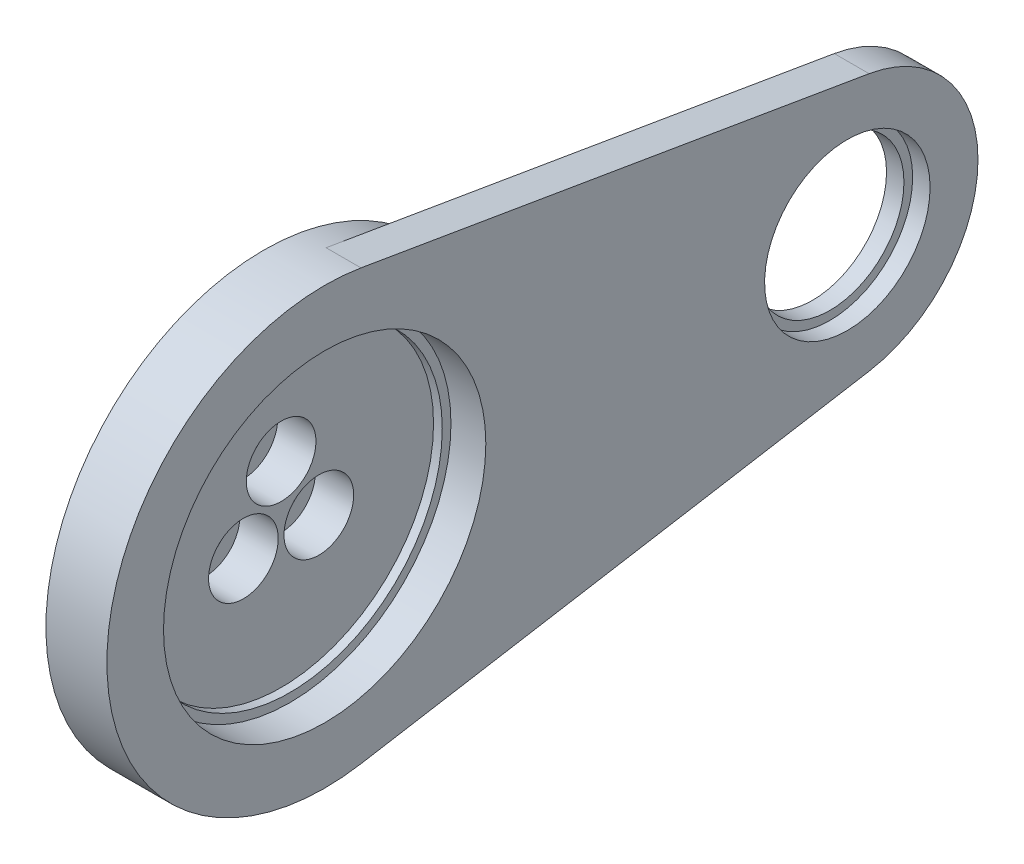
from build123d import *

# Parameters (mm, degrees)
SKETCH_3_R                   = 25
EXTRUDE_1_DEPTH              = 2
SKETCH_4_R                   = 25
SKETCH_4_R_2                 = 17.5
EXTRUDE_2_DEPTH              = 1
SKETCH_5_R                   = 25
SKETCH_5_R_2                 = 18.5
EXTRUDE_3_DEPTH              = 7
SKETCH_6_R                   = 25
SKETCH_6_R_2                 = 17.5
EXTRUDE_4_DEPTH              = 2
EXTRUDE_5_DEPTH              = 9
SKETCH_11_R                  = 8.5
CUT_EXTRUDE_3_DEPTH          = 111
SKETCH_12_R                  = 9.5
CUT_EXTRUDE_4_DEPTH          = 2.5
SKETCH_13_R                  = 9.5
EXTRUDE_6_DEPTH              = 5
HOLE_WIZARD_M4_1_D           = 4.5
HOLE_WIZARD_M4_1_CBORE_D     = 8
HOLE_WIZARD_M4_1_CBORE_DEPTH = 4.4
PATTERN_CIRCULAR_1_COUNT     = 3
SKETCH_17_W                  = 17.714059585
SKETCH_17_H                  = 64.604217311
CUT_EXTRUDE_5_DEPTH          = 1111


with BuildPart() as part:
    # 스케치3 → 보스-돌출1 (new body)
    with BuildSketch(Plane(origin=(0, 0, 0), x_dir=(0, 0, -1), z_dir=(1, 0, 0))):
        Circle(SKETCH_3_R)
    extrude(amount=EXTRUDE_1_DEPTH)

    # 스케치4 → 보스-돌출2 (add)
    with BuildSketch(Plane(origin=(2, 0, 0), x_dir=(0, 0, -1), z_dir=(1, 0, 0))):
        Circle(SKETCH_4_R)
        Circle(SKETCH_4_R_2, mode=Mode.SUBTRACT)
    extrude(amount=EXTRUDE_2_DEPTH)

    # 스케치5 → 보스-돌출3 (add)
    with BuildSketch(Plane(origin=(3, 0, 0), x_dir=(0, 0, -1), z_dir=(1, 0, 0))):
        Circle(SKETCH_5_R)
        Circle(SKETCH_5_R_2, mode=Mode.SUBTRACT)
    extrude(amount=EXTRUDE_3_DEPTH)

    # 스케치6 → 보스-돌출4 (add)
    with BuildSketch(Plane(origin=(10, 0, 0), x_dir=(0, 0, -1), z_dir=(1, 0, 0))):
        Circle(SKETCH_6_R)
        Circle(SKETCH_6_R_2, mode=Mode.SUBTRACT)
    extrude(amount=EXTRUDE_4_DEPTH)

    # 스케치10 → 보스-돌출5 (add)
    with BuildSketch(Plane(origin=(12, 0, 0), x_dir=(0, 0, -1), z_dir=(1, 0, 0))):
        with BuildLine():
            Line((4.166666667, 24.65033243), (62.5, 14.790199458))
            ThreePointArc((62.5, 14.790199458), (75, 0), (62.5, -14.790199458))
            Line((62.5, -14.790199458), (4.166666667, -24.65033243))
            ThreePointArc((4.166666667, -24.65033243), (25, 0), (4.166666667, 24.65033243))
        make_face()
    extrude(amount=-EXTRUDE_5_DEPTH)

    # 스케치11 → 컷-돌출3 (cut, symmetric)
    with BuildSketch(Plane(origin=(7.5, 0, 0), x_dir=(0, 0, -1), z_dir=(1, 0, 0))):
        with Locations((60, 0)):
            Circle(SKETCH_11_R)
    extrude(amount=CUT_EXTRUDE_3_DEPTH, both=True, mode=Mode.SUBTRACT)

    # 스케치12 → 컷-돌출4 (cut, symmetric)
    with BuildSketch(Plane(origin=(7.5, 0, 0), x_dir=(0, 0, -1), z_dir=(1, 0, 0))):
        with Locations((60, 0)):
            Circle(SKETCH_12_R)
    extrude(amount=CUT_EXTRUDE_4_DEPTH, both=True, mode=Mode.SUBTRACT)

    # 스케치13 → 보스-돌출6 (add)
    with BuildSketch(Plane.ZY):
        Circle(SKETCH_13_R)
    extrude(amount=EXTRUDE_6_DEPTH)

    # M4 육각 소켓 머리 캡 나사용 카운터보어1 (through all)
    with Locations(Plane(origin=(2, 0, 0), x_dir=(0, 0, -1), z_dir=(1, 0, 0))):
        with Locations((0, 5)):
            hole_wizard_m4_1 = CounterBoreHole(HOLE_WIZARD_M4_1_D / 2, HOLE_WIZARD_M4_1_CBORE_D / 2, HOLE_WIZARD_M4_1_CBORE_DEPTH)

    # 원형 패턴1: M4 육각 소켓 머리 캡 나사용 카운터보어1 ×3 about axis
    pattern_circular_1_axis = Axis((0, 0, 0), (1, 0, 0))
    for i in range(1, PATTERN_CIRCULAR_1_COUNT):
        add(hole_wizard_m4_1.rotate(pattern_circular_1_axis, i * 360 / PATTERN_CIRCULAR_1_COUNT), mode=Mode.SUBTRACT)

    # 스케치17 → 컷-돌출5 (cut, symmetric)
    with BuildSketch(Plane.XY):
        with Locations((15.857029793, -1.852450676)):
            Rectangle(SKETCH_17_W, SKETCH_17_H)
    extrude(amount=CUT_EXTRUDE_5_DEPTH, both=True, mode=Mode.SUBTRACT)


solid = part.part
